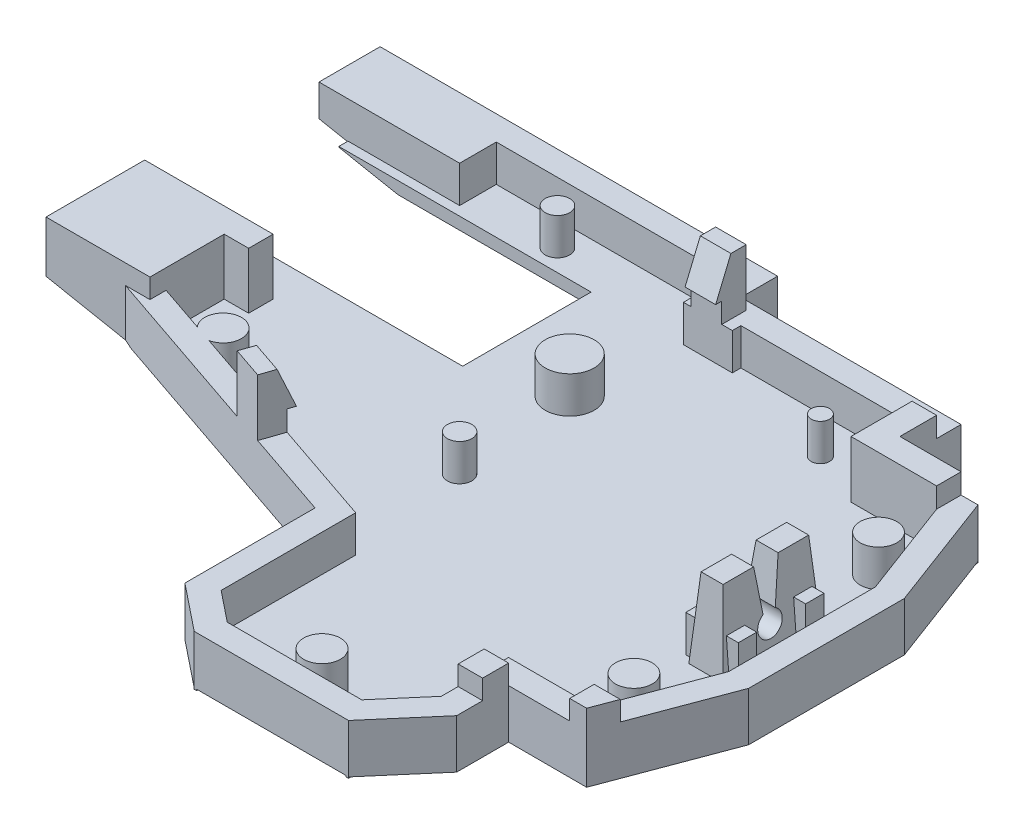
from build123d import *

# Parameters (mm, degrees)
SKETCH13_W           = 50
SKETCH13_H           = 45
BOSS_EXTRUDE4_DEPTH  = 1.6
SKETCH14_W           = 10
SKETCH14_H           = 8
CUT_EXTRUDE6_DEPTH   = 2.6
SKETCH15_W           = 18
SKETCH15_H           = 3
CUT_EXTRUDE7_DEPTH   = 2.6
SKETCH16_W           = 4
SKETCH16_H           = 0.7
CUT_EXTRUDE8_DEPTH   = 2.6
CUT_EXTRUDE9_DEPTH   = 2.6
SKETCH18_W           = 21.109590793
SKETCH18_H           = 22.840524871
CUT_EXTRUDE10_DEPTH  = 2.6
CUT_EXTRUDE11_DEPTH  = 2.6
SKETCH22_W           = 2
SKETCH22_H           = 3
CUT_EXTRUDE12_DEPTH  = 2.6
CUT_EXTRUDE13_DEPTH  = 2.6
CUT_EXTRUDE14_DEPTH  = 2.6
SKETCH25_W           = 2.8
SKETCH25_H           = 8
CUT_EXTRUDE15_DEPTH  = 2.6
BOSS_EXTRUDE6_DEPTH  = 6
SKETCH30_W           = 2.8
SKETCH30_H           = 8
BOSS_EXTRUDE7_DEPTH  = 3.5
CUT_EXTRUDE16_DEPTH  = 4.6
SKETCH32_W           = 2.8
SKETCH32_H           = 8
BOSS_EXTRUDE8_DEPTH  = 4.6
CUT_EXTRUDE18_DEPTH  = 4.6
SKETCH37_R           = 1
CUT_EXTRUDE19_DEPTH  = 4.6
CUT_EXTRUDE20_DEPTH  = 4.6
CUT_EXTRUDE21_START  = 6
CUT_EXTRUDE21_DEPTH  = 20.059798
BOSS_EXTRUDE9_DEPTH  = 4.6
SKETCH44_W           = 4.3
SKETCH44_H           = 1.5
BOSS_EXTRUDE11_DEPTH = 3
SKETCH45_R           = 1.5
SKETCH45_R_2         = 1
SKETCH45_R_3         = 1.999622229
SKETCH45_R_4         = 1.503341979
SKETCH45_R_5         = 0.75
BOSS_EXTRUDE12_DEPTH = 3
SKETCH46_W           = 2.5
SKETCH46_H           = 2
SKETCH46_W_2         = 2
BOSS_EXTRUDE13_DEPTH = 1.65
SKETCH47_W           = 3
SKETCH47_H           = 3
BOSS_EXTRUDE14_DEPTH = 3
SKETCH48_W           = 2
SKETCH48_H           = 16.336241737
CUT_EXTRUDE22_DEPTH  = 3
SKETCH49_W           = 21.336241737
SKETCH49_H           = 3
BOSS_EXTRUDE15_DEPTH = 13
SKETCH50_W           = 67
SKETCH50_H           = 49
BOSS_EXTRUDE16_DEPTH = 3
SKETCH51_W           = 5
SKETCH51_H           = 11
BOSS_EXTRUDE17_DEPTH = 15.6
CUT_EXTRUDE23_DEPTH  = 1.65
SKETCH53_W           = 2
SKETCH53_H           = 2.129349353
BOSS_EXTRUDE18_DEPTH = 1.6
SKETCH55_W           = 2.5
SKETCH55_H           = 2.5
BOSS_EXTRUDE20_DEPTH = 3
CUT_EXTRUDE24_DEPTH  = 3
SKETCH58_W           = 20
SKETCH58_H           = 10.5
SKETCH58_W_2         = 2
SKETCH58_H_2         = 2
CUT_EXTRUDE29_DEPTH  = 1
BOSS_EXTRUDE21_DEPTH = 3
BOSS_EXTRUDE22_REACH = 41.731
SKETCH61_W           = 2.5
SKETCH61_H           = 1.65
CUT_EXTRUDE30_DEPTH  = 3
CUT_EXTRUDE31_REACH  = 43.731
SKETCH64_W           = 2.551500858
SKETCH64_H           = 4.310788114
CUT_EXTRUDE32_DEPTH  = 4.65
SKETCH65_W           = 2
SKETCH65_H           = 2
BOSS_EXTRUDE23_DEPTH = 4
SKETCH66_W           = 2
SKETCH66_H           = 2
BOSS_EXTRUDE24_DEPTH = 1.6
SKETCH67_W           = 2.5
SKETCH67_H           = 2
BOSS_EXTRUDE25_DEPTH = 3
CUT_EXTRUDE33_DEPTH  = 3
BOSS_EXTRUDE26_DEPTH = 1.65
SKETCH70_W           = 5.055009343
SKETCH70_H           = 5.560438358
CUT_EXTRUDE34_DEPTH  = 3
BOSS_EXTRUDE27_DEPTH = 3
CUT_EXTRUDE35_DEPTH  = 3
BOSS_EXTRUDE28_REACH = 39.863
CUT_EXTRUDE36_DEPTH  = 3
FILLET8_R            = 1
SKETCH76_W           = 7
SKETCH76_H           = 14.5
BOSS_EXTRUDE29_DEPTH = 14.5
BOSS_EXTRUDE30_DEPTH = 2
CUT_EXTRUDE37_DEPTH  = 2
BOSS_EXTRUDE31_DEPTH = 2.684479
SKETCH85_W           = 30.566158209
SKETCH85_H           = 1.725230041
BOSS_EXTRUDE33_DEPTH = 3
BOSS_EXTRUDE34_DEPTH = 3
BOSS_EXTRUDE35_DEPTH = 3
SKETCH88_W           = 27.09375
SKETCH88_H           = 14.5
BOSS_EXTRUDE36_DEPTH = 1.6
SKETCH90_W           = 7
SKETCH90_H           = 14.5
BOSS_EXTRUDE37_DEPTH = 1.6
SKETCH93_W           = 5
SKETCH93_H           = 11
BOSS_EXTRUDE38_DEPTH = 0.5
SKETCH94_W           = 8.605758832
SKETCH94_H           = 2
BOSS_EXTRUDE39_DEPTH = 15.6
SKETCH96_W           = 8.605758832
SKETCH96_H           = 2
BOSS_EXTRUDE40_DEPTH = 0.5
SKETCH97_W           = 2
SKETCH97_H           = 49
BOSS_EXTRUDE41_DEPTH = 19.1
SKETCH98_W           = 69
SKETCH98_H           = 2
BOSS_EXTRUDE42_DEPTH = 19.1
SKETCH99_W           = 2
SKETCH99_H           = 3
BOSS_EXTRUDE43_DEPTH = 2.087376
SKETCH100_W          = 2
SKETCH100_H          = 51
BOSS_EXTRUDE45_DEPTH = 19.1
SKETCH101_W          = 71
SKETCH101_H          = 2
BOSS_EXTRUDE46_DEPTH = 19.1
BOSS_EXTRUDE47_DEPTH = 16.1
BOSS_EXTRUDE48_DEPTH = 16.1
FILLET9_R            = 2
SKETCH105_OUTSIDE_W  = 91.128
SKETCH105_OUTSIDE_H  = 73.128
CUT_EXTRUDE38_DEPTH  = 3
SKETCH106_W          = 77.0560479
SKETCH106_H          = 58.523580684
CUT_EXTRUDE39_DEPTH  = 20.1
SKETCH107_W          = 13.37564089
SKETCH107_H          = 6.179627402
CUT_EXTRUDE40_DEPTH  = 11.5
CUT_EXTRUDE41_DEPTH  = 4
SKETCH114_W          = 66.336817547
SKETCH114_H          = 51.668552302
CUT_EXTRUDE42_DEPTH  = 2
BOSS_EXTRUDE49_DEPTH = 6.5
SKETCH116_W          = 0.628599621
SKETCH116_H          = 10.5
CUT_EXTRUDE43_DEPTH  = 6.5
SKETCH117_W          = 8.5
SKETCH117_H          = 8.070282703
BOSS_EXTRUDE50_DEPTH = 1.6
SKETCH121_W          = 41.947556189
SKETCH121_H          = 104.538908281
CUT_EXTRUDE44_DEPTH  = 2.374278057
SKETCH122_W          = 0.2
SKETCH122_H          = 0.2
BOSS_EXTRUDE51_DEPTH = 0.1


with BuildPart() as part:
    # Sketch13 → Boss-Extrude4 (new body)
    with BuildSketch(Plane(origin=(0, 0, 0), x_dir=(1, 0, 0), z_dir=(0, 1, 0))):
        with Locations((25, -22.5)):
            Rectangle(SKETCH13_W, SKETCH13_H)
    extrude(amount=BOSS_EXTRUDE4_DEPTH)

    # Sketch14 → Cut-Extrude6 (cut, through all)
    with BuildSketch(Plane(origin=(0, 1.6, 0), x_dir=(1, 0, 0), z_dir=(0, 1, 0))):
        with Locations((45, -4)):
            Rectangle(SKETCH14_W, SKETCH14_H)
    extrude(amount=-CUT_EXTRUDE6_DEPTH, mode=Mode.SUBTRACT)

    # Sketch15 → Cut-Extrude7 (cut, through all)
    with BuildSketch(Plane(origin=(0, 1.6, 0), x_dir=(1, 0, 0), z_dir=(0, 1, 0))):
        with Locations((31, -1.5)):
            Rectangle(SKETCH15_W, SKETCH15_H)
    extrude(amount=-CUT_EXTRUDE7_DEPTH, mode=Mode.SUBTRACT)

    # Sketch16 → Cut-Extrude8 (cut, through all)
    with BuildSketch(Plane(origin=(0, 1.6, 0), x_dir=(1, 0, 0), z_dir=(0, 1, 0))):
        with Locations((24, -3.35)):
            Rectangle(SKETCH16_W, SKETCH16_H)
    extrude(amount=-CUT_EXTRUDE8_DEPTH, mode=Mode.SUBTRACT)

    # Sketch17 → Cut-Extrude9 (cut, through all)
    with BuildSketch(Plane(origin=(0, 1.6, 0), x_dir=(1, 0, 0), z_dir=(0, 1, 0))):
        Polygon((47, -8), (50, -16), (65.881056194, -16), (65.881056194, 17.957346821), (47, 17.957346821), align=None)
    extrude(amount=-CUT_EXTRUDE9_DEPTH, mode=Mode.SUBTRACT)

    # Sketch18 → Cut-Extrude10 (cut, through all)
    with BuildSketch(Plane(origin=(0, 1.6, 0), x_dir=(1, 0, 0), z_dir=(0, 1, 0))):
        with Locations((50.554795396, -47.420262436)):
            Rectangle(SKETCH18_W, SKETCH18_H)
    extrude(amount=-CUT_EXTRUDE10_DEPTH, mode=Mode.SUBTRACT)

    # Sketch21 → Cut-Extrude11 (cut, through all)
    with BuildSketch(Plane(origin=(0, 1.6, 0), x_dir=(1, 0, 0), z_dir=(0, 1, 0))):
        Polygon((50, -28), (47, -36), (47, -49.297594069), (75.196774358, -49.297594069), (75.196774358, -28), align=None)
    extrude(amount=-CUT_EXTRUDE11_DEPTH, mode=Mode.SUBTRACT)

    # Sketch22 → Cut-Extrude12 (cut, through all)
    with BuildSketch(Plane(origin=(0, 1.6, 0), x_dir=(1, 0, 0), z_dir=(0, 1, 0))):
        with Locations((1, -20.836241737)):
            Rectangle(SKETCH22_W, SKETCH22_H)
    extrude(amount=-CUT_EXTRUDE12_DEPTH, mode=Mode.SUBTRACT)

    # Sketch23 → Cut-Extrude13 (cut, through all)
    with BuildSketch(Plane(origin=(0, 1.6, 0), x_dir=(1, 0, 0), z_dir=(0, 1, 0))):
        Polygon((23.5, -45), (23.5, -32), (0, -26.336241737), (-30.2261683, -26.336241737), (-30.2261683, -63.188280898), (23.5, -63.188280898), align=None)
    extrude(amount=-CUT_EXTRUDE13_DEPTH, mode=Mode.SUBTRACT)

    # Sketch24 → Cut-Extrude14 (cut, through all)
    with BuildSketch(Plane(origin=(0, 1.6, 0), x_dir=(1, 0, 0), z_dir=(0, 1, 0))):
        Polygon((23.5, -43), (7.491129632, -43), (7.491129632, -69.550234766), (44.754002286, -69.550234766), (44.754002286, -41.5), (40, -41.5), (37, -45), (26, -45), align=None)
    extrude(amount=-CUT_EXTRUDE14_DEPTH, mode=Mode.SUBTRACT)

    # Sketch25 → Cut-Extrude15 (cut, through all)
    with BuildSketch(Plane(origin=(0, 1.6, 0), x_dir=(1, 0, 0), z_dir=(0, 1, 0))):
        with Locations((46.200745069, -22.059797812)):
            Rectangle(SKETCH25_W, SKETCH25_H)
    extrude(amount=-CUT_EXTRUDE15_DEPTH, mode=Mode.SUBTRACT)

    # Sketch28 → Boss-Extrude6 (add)
    with BuildSketch(Plane.XZ):
        Polygon((42, 38), (42, 42.239848152), (37.919869845, 47), (25.298437881, 47), (21.5, 43.961249695), (21.5, 33.575244456), (-2, 27.911486193), (-2, -2), (24, -2), (24, 1), (42, 1), (42, 6), (48.386000936, 6), (52, 15.637330836), (52, 28.362669164), (48.386000936, 38), align=None)
    extrude(amount=BOSS_EXTRUDE6_DEPTH)

    # Sketch30 → Boss-Extrude7 (add)
    with BuildSketch(Plane(origin=(0, 0, 0), x_dir=(1, 0, 0), z_dir=(0, 1, 0))):
        with Locations((46.200745069, -22.059797812)):
            Rectangle(SKETCH30_W, SKETCH30_H)
    extrude(amount=BOSS_EXTRUDE7_DEPTH)

    # Sketch31 → Cut-Extrude16 (cut)
    with BuildSketch(Plane(origin=(0, 1.6, 0), x_dir=(1, 0, 0), z_dir=(0, 1, 0))):
        Polygon((37, -45), (40, -41.5), (40, -36), (47, -36), (50, -28), (50, -16), (47, -8), (40, -8), (40, -3), (26, -3), (26, -3.7), (22, -3.7), (22, 0), (0, 0), (0, -19.336241737), (2, -19.336241737), (2, -22.336241737), (0, -22.336241737), (0, -26.336241737), (23.5, -32), (23.5, -43), (26, -45), align=None)
    extrude(amount=-CUT_EXTRUDE16_DEPTH, mode=Mode.SUBTRACT)

    # Sketch32 → Boss-Extrude8 (add)
    with BuildSketch(Plane.XZ.offset(-1.6)):
        with Locations((46.200745069, 22.059797812)):
            Rectangle(SKETCH32_W, SKETCH32_H)
    extrude(amount=BOSS_EXTRUDE8_DEPTH)

    # Sketch35 → Cut-Extrude18 (cut)
    with BuildSketch(Plane(origin=(47.600745069, 0, 0), x_dir=(0, 0, -1), z_dir=(1, 0, 0))):
        Polygon((-22.059797812, 0), (-21.559797812, 0), (-21.059797812, 3.5), (-21.297672794, 5.165124873), (-23.257672794, 4.885124873), (-23.059797812, 3.5), (-22.559797812, 0), align=None)
    extrude(amount=-CUT_EXTRUDE18_DEPTH, mode=Mode.SUBTRACT)

    # Sketch37 → Cut-Extrude19 (cut)
    with BuildSketch(Plane(origin=(47.600745069, 0, 0), x_dir=(0, 0, -1), z_dir=(1, 0, 0))):
        with Locations((-22.059797812, -0.866025404)):
            Circle(SKETCH37_R)
    extrude(amount=-CUT_EXTRUDE19_DEPTH, mode=Mode.SUBTRACT)

    # Sketch39 → Cut-Extrude20 (cut)
    with BuildSketch(Plane.ZY.offset(-44.800745069)):
        Polygon((25.559797812, 3.5), (26.059797812, -3), (27.906381513, -2.8579551), (27.406381513, 3.6420449), align=None)
        Polygon((18.559797812, 3.5), (18.059797812, -3), (15.957253652, -2.838265834), (16.455739093, 3.6420449), align=None)
    extrude(amount=-CUT_EXTRUDE20_DEPTH, mode=Mode.SUBTRACT)

    # Sketch41 → Cut-Extrude21 (cut)
    with BuildSketch(Plane.XY.offset(CUT_EXTRUDE21_START)):
        Polygon((45.300745069, 3.5), (44.800745069, -3), (43.414957387, -2.893400947), (43.940591177, 3.939838325), align=None)
        Polygon((47.100745069, 3.5), (47.600745069, -3), (49.658968536, -2.841675118), (49.137313656, 3.939838325), align=None)
    extrude(amount=CUT_EXTRUDE21_DEPTH, mode=Mode.SUBTRACT)

    # Sketch43 → Boss-Extrude9 (add)
    with BuildSketch(Plane(origin=(0, 0, 0), x_dir=(1, 0, 0), z_dir=(0, 1, 0))):
        Polygon((47, -8), (50, -16), (51.170411472, -13.425094762), (48.386000936, -6), (42.818763345, -6), (42.818763345, -8), align=None)
    extrude(amount=-BOSS_EXTRUDE9_DEPTH)

    # Sketch44 → Boss-Extrude11 (add)
    with BuildSketch(Plane(origin=(0, -3, 0), x_dir=(1, 0, 0), z_dir=(0, 1, 0))):
        with Locations((46.200745069, -19.309797812)):
            Rectangle(SKETCH44_W, SKETCH44_H)
        with Locations((46.200745069, -24.809797812)):
            Rectangle(SKETCH44_W, SKETCH44_H)
    extrude(amount=BOSS_EXTRUDE11_DEPTH)

    # Sketch45 → Boss-Extrude12 (add)
    with BuildSketch(Plane(origin=(0, -3, 0), x_dir=(1, 0, 0), z_dir=(0, 1, 0))):
        with Locations((46.25, -12)):
            Circle(SKETCH45_R)
        with Locations((46.25, -32)):
            Circle(SKETCH45_R)
        with Locations((22, -22)):
            Circle(SKETCH45_R_2)
        with Locations((21, -12)):
            Circle(SKETCH45_R_3)
        with Locations((31.75, -43)):
            Circle(SKETCH45_R_4)
        with Locations((35.5, -6)):
            Circle(SKETCH45_R_5)
        with Locations((10, -2)):
            Circle(SKETCH45_R_2)
        with Locations((5, -24.336241737)):
            Circle(SKETCH45_R)
    extrude(amount=BOSS_EXTRUDE12_DEPTH)

    # Sketch46 → Boss-Extrude13 (add)
    with BuildSketch(Plane(origin=(0, 0, 0), x_dir=(1, 0, 0), z_dir=(0, 1, 0))):
        Polygon((14.137316506, -29.743490383), (16.567726059, -30.329245795), (16.099121729, -32.273573438), (13.668712176, -31.687818026), align=None)
        with Locations((23.883625006, -2.7)):
            Rectangle(SKETCH46_W, SKETCH46_H)
        with Locations((1, -20.932723283)):
            Rectangle(SKETCH46_W_2, SKETCH46_H)
        Polygon((47, -36), (48.872658355, -36.702246883), (49.750466959, -34.361423939), (47.877808604, -33.659177056), align=None)
        Polygon((40, -3), (40, -8), (47, -8), (47, -6), (42, -6), (42, -3), align=None)
    extrude(amount=BOSS_EXTRUDE13_DEPTH)

    # Sketch47 → Boss-Extrude14 (add)
    with BuildSketch(Plane(origin=(0, 0, 0), x_dir=(1, 0, 0), z_dir=(0, 1, 0))):
        with Locations((1.5, -1.5)):
            Rectangle(SKETCH47_W, SKETCH47_H)
    extrude(amount=-BOSS_EXTRUDE14_DEPTH)

    # Sketch48 → Cut-Extrude22 (cut)
    with BuildSketch(Plane(origin=(0, 0, 0), x_dir=(1, 0, 0), z_dir=(0, 1, 0))):
        with Locations((-1, -11.168120869)):
            Rectangle(SKETCH48_W, SKETCH48_H)
    extrude(amount=-CUT_EXTRUDE22_DEPTH, mode=Mode.SUBTRACT)

    # Sketch49 → Boss-Extrude15 (add)
    with BuildSketch(Plane.ZY.offset(2)):
        with Locations((8.668120869, -4.5)):
            Rectangle(SKETCH49_W, SKETCH49_H)
    extrude(amount=BOSS_EXTRUDE15_DEPTH)

    # Sketch50 → Boss-Extrude16 (add)
    with BuildSketch(Plane.XZ.offset(6)):
        with Locations((18.5, 22.5)):
            Rectangle(SKETCH50_W, SKETCH50_H)
    extrude(amount=-BOSS_EXTRUDE16_DEPTH)

    # Sketch51 → Boss-Extrude17 (add)
    with BuildSketch(Plane(origin=(0, -3, 0), x_dir=(1, 0, 0), z_dir=(0, 1, 0))):
        with Locations((49.5, -41.5)):
            Rectangle(SKETCH51_W, SKETCH51_H)
    extrude(amount=BOSS_EXTRUDE17_DEPTH)

    # Sketch52 → Cut-Extrude23 (cut)
    with BuildSketch(Plane(origin=(0, 1.65, 0), x_dir=(1, 0, 0), z_dir=(0, 1, 0))):
        Polygon((47.877808604, -33.659177056), (47, -36), (49.136000936, -36), (49.750466959, -34.361423939), align=None)
    extrude(amount=-CUT_EXTRUDE23_DEPTH, mode=Mode.SUBTRACT)

    # Sketch53 → Boss-Extrude18 (add)
    with BuildSketch(Plane(origin=(0, 0, 0), x_dir=(1, 0, 0), z_dir=(0, 1, 0))):
        with Locations((41, -39.055249399)):
            Rectangle(SKETCH53_W, SKETCH53_H)
    extrude(amount=BOSS_EXTRUDE18_DEPTH)

    # Sketch55 → Boss-Extrude20 (add)
    with BuildSketch(Plane(origin=(0, 1.65, 0), x_dir=(1, 0, 0), z_dir=(0, 1, 0))):
        with Locations((23.883625006, -2.95)):
            Rectangle(SKETCH55_W, SKETCH55_H)
    extrude(amount=BOSS_EXTRUDE20_DEPTH)

    # Sketch56 → Cut-Extrude24 (cut)
    with BuildSketch(Plane(origin=(25.133625006, 0, 0), x_dir=(0, 0, -1), z_dir=(1, 0, 0))):
        Polygon((-4.2, 1.65), (-2.95, 4.65), (-2.95, 7.68728323), (-6.59715338, 7.68728323), (-6.59715338, 1.641289328), align=None)
    extrude(amount=-CUT_EXTRUDE24_DEPTH, mode=Mode.SUBTRACT)

    # Sketch58 → Cut-Extrude29 (cut)
    with BuildSketch(Plane(origin=(0, -3, 0), x_dir=(1, 0, 0), z_dir=(0, 1, 0))):
        with Locations((4.5, -9)):
            Rectangle(SKETCH58_W, SKETCH58_H)
        with Locations((1, -18.248866233)):
            Rectangle(SKETCH58_W_2, SKETCH58_H_2)
    extrude(amount=-CUT_EXTRUDE29_DEPTH, mode=Mode.SUBTRACT)

    # Sketch60 → Boss-Extrude21 (add)
    with BuildSketch(Plane(origin=(0, -3, 0), x_dir=(1, 0, 0), z_dir=(0, 1, 0))):
        Polygon((0, -24), (23.5, -32), (0, -26.336241737), align=None)
    extrude(amount=BOSS_EXTRUDE21_DEPTH)

    # Boss-Extrude22: up to this face of the body (flat: up to its plane)
    boss_extrude22_end = Plane(part.part.faces().sort_by_distance((14.401539714, -1.5, 28.902651818))[0])
    # Sketch61 → Boss-Extrude22 (add, up to the picked face)
    with BuildSketch(Plane(origin=(-5.998871461, 0, 24.890447788), x_dir=(-0.972163821, 0, -0.234302165), z_dir=(0.234302165, 0, -0.972163821)), mode=Mode.PRIVATE) as boss_extrude22_sk1:
        with Locations((-21.962751827, 0.825)):
            Rectangle(SKETCH61_W, SKETCH61_H)
    boss_extrude22_tool1 = split(extrude(boss_extrude22_sk1.sketch, amount=BOSS_EXTRUDE22_REACH, mode=Mode.PRIVATE), bisect_by=boss_extrude22_end, keep=Keep.BOTH, mode=Mode.PRIVATE)
    add(boss_extrude22_tool1.solids().sort_by_distance((15.352521, 0.825, 30.036368))[0])

    # Sketch62 → Cut-Extrude30 (cut)
    with BuildSketch(Plane(origin=(0, 0, 0), x_dir=(1, 0, 0), z_dir=(0, 1, 0))):
        Polygon((0, -26), (-0.545193502, -28.262110548), (-9.931116312, -26), (-9.25988925, -22.847697277), align=None)
    extrude(amount=-CUT_EXTRUDE30_DEPTH, mode=Mode.SUBTRACT)

    # Cut-Extrude31: up to this face of the body (flat: up to its plane)
    cut_extrude31_end = Plane(part.part.faces().sort_by_distance((-1, -1.5, 25.659574468))[0])
    # Sketch63 → Cut-Extrude31 (cut, up to the picked face)
    with BuildSketch(Plane(origin=(-6.46747579, 0, 26.834775431), x_dir=(0.972163821, 0, 0.234302165), z_dir=(-0.234302165, 0, 0.972163821)), mode=Mode.PRIVATE) as cut_extrude31_sk1:
        Polygon((20.712751827, 0), (6.091856288, 0), (6.091856288, -3), (28.768274623, -3), (28.768274623, 0), (23.212751827, 0), (23.212751827, 1.65), (20.712751827, 1.65), align=None)
    cut_extrude31_tool1 = split(extrude(cut_extrude31_sk1.sketch, amount=-CUT_EXTRUDE31_REACH, mode=Mode.PRIVATE), bisect_by=cut_extrude31_end, keep=Keep.BOTH, mode=Mode.PRIVATE)
    add(cut_extrude31_tool1.solids().sort_by_distance((10.72932, -1.367082, 30.979392))[0], mode=Mode.SUBTRACT)

    # Sketch64 → Cut-Extrude32 (cut)
    with BuildSketch(Plane(origin=(0, 1.65, 0), x_dir=(1, 0, 0), z_dir=(0, 1, 0))):
        with Locations((1.275750429, -20.806985271)):
            Rectangle(SKETCH64_W, SKETCH64_H)
    extrude(amount=-CUT_EXTRUDE32_DEPTH, mode=Mode.SUBTRACT)

    # Sketch65 → Boss-Extrude23 (add)
    with BuildSketch(Plane(origin=(0, -4, 0), x_dir=(1, 0, 0), z_dir=(0, 1, 0))):
        with Locations((1, -18.248866233)):
            Rectangle(SKETCH65_W, SKETCH65_H)
    extrude(amount=BOSS_EXTRUDE23_DEPTH)

    # Sketch66 → Boss-Extrude24 (add)
    with BuildSketch(Plane(origin=(0, 0, 0), x_dir=(1, 0, 0), z_dir=(0, 1, 0))):
        with Locations((1, -18.248866233)):
            Rectangle(SKETCH66_W, SKETCH66_H)
    extrude(amount=BOSS_EXTRUDE24_DEPTH)

    # Sketch67 → Boss-Extrude25 (add)
    with BuildSketch(Plane(origin=(0, 1.6, 0), x_dir=(1, 0, 0), z_dir=(0, 1, 0))):
        with Locations((1.25, -18.248866233)):
            Rectangle(SKETCH67_W, SKETCH67_H)
    extrude(amount=BOSS_EXTRUDE25_DEPTH)

    # Sketch68 → Cut-Extrude33 (cut)
    with BuildSketch(Plane(origin=(0, 0, 17.248866233), x_dir=(-1, 0, 0), z_dir=(0, 0, -1))):
        Polygon((-2.5, 1.6), (-1.25, 4.6), (-1.25, 6.77486743), (-4.497451498, 6.77486743), (-4.497451498, 1.567063174), align=None)
    extrude(amount=-CUT_EXTRUDE33_DEPTH, mode=Mode.SUBTRACT)

    # Sketch69 → Boss-Extrude26 (add)
    with BuildSketch(Plane(origin=(0, 1.65, 0), x_dir=(1, 0, 0), z_dir=(0, 1, 0))):
        Polygon((14.344636536, -28.883280523), (16.885898362, -29.748390932), (16.275756374, -31.540683021), (13.734494548, -30.675572612), align=None)
    extrude(amount=-BOSS_EXTRUDE26_DEPTH)

    # Sketch70 → Cut-Extrude34 (cut)
    with BuildSketch(Plane.XY.offset(19.248866233)):
        with Locations((-0.027504672, 4.380219179)):
            Rectangle(SKETCH70_W, SKETCH70_H)
    extrude(amount=-CUT_EXTRUDE34_DEPTH, mode=Mode.SUBTRACT)

    # Sketch71 → Boss-Extrude27 (add)
    with BuildSketch(Plane(origin=(0, 1.65, 0), x_dir=(1, 0, 0), z_dir=(0, 1, 0))):
        Polygon((16.275756374, -31.540683021), (17.081415869, -29.174058256), (14.559846057, -28.298525857), (13.734494548, -30.675572612), align=None)
    extrude(amount=BOSS_EXTRUDE27_DEPTH)

    # Sketch72 → Cut-Extrude35 (cut)
    with BuildSketch(Plane(origin=(24.207602216, 0, 8.240885861), x_dir=(0.322263798, 0, -0.946649906), z_dir=(0.946649906, 0, 0.322263798))):
        Polygon((-22.112897557, 1.65), (-23.362897557, 4.65), (-23.362897557, 7.694800469), (-20.734818485, 7.694800469), (-20.734818485, 1.65), align=None)
    extrude(amount=-CUT_EXTRUDE35_DEPTH, mode=Mode.SUBTRACT)

    # Boss-Extrude28: up to this face of the body (flat: up to its plane)
    boss_extrude28_end = Plane(part.part.faces().sort_by_distance((14.039565542, 0.825, 29.779426567))[0])
    # Sketch73 → Boss-Extrude28 (add, up to the picked face)
    with BuildSketch(Plane(origin=(21.761963317, 0, 7.556127878), x_dir=(-0.328007452, 0, 0.944675136), z_dir=(-0.944675136, 0, -0.328007452)), mode=Mode.PRIVATE) as boss_extrude28_sk1:
        Polygon((24.473434161, 4.65), (23.223411105, 4.65), (21.973388049, 1.65), (22.580099427, 1.65), (24.473434161, 1.65), align=None)
    boss_extrude28_tool1 = split(extrude(boss_extrude28_sk1.sketch, amount=BOSS_EXTRUDE28_REACH, mode=Mode.PRIVATE), bisect_by=boss_extrude28_end, keep=Keep.BOTH, mode=Mode.PRIVATE)
    add(boss_extrude28_tool1.solids().sort_by_distance((14.053397, 2.983333, 29.757122))[0])

    # Sketch74 → Cut-Extrude36 (cut)
    with BuildSketch(Plane(origin=(0, -4, 0), x_dir=(1, 0, 0), z_dir=(0, 1, 0))):
        with BuildLine():
            Line((6.419171569, -6.169171569), (2.580828431, -6.169171569))
            ThreePointArc((2.580828431, -6.169171569), (-0.25, -9), (2.580828431, -11.830828431))
            Line((2.580828431, -11.830828431), (6.419171569, -11.830828431))
            ThreePointArc((6.419171569, -11.830828431), (9.25, -9), (6.419171569, -6.169171569))
        make_face()
    extrude(amount=-CUT_EXTRUDE36_DEPTH, mode=Mode.SUBTRACT)

    # Fillet8
    fillet8_edges = [part.edges().sort_by_distance(p)[0] for p in [
        (-0.25, -6, 9),
        (4.5, -6, 6.169171569),
        (9.25, -6, 9),
        (4.5, -6, 11.830828431),
    ]]
    fillet(fillet8_edges, radius=FILLET8_R)

    # Sketch76 → Boss-Extrude29 (add)
    with BuildSketch(Plane(origin=(0, -3, 0), x_dir=(1, 0, 0), z_dir=(0, 1, 0))):
        with Locations((-11.5, -39.75)):
            Rectangle(SKETCH76_W, SKETCH76_H)
    extrude(amount=BOSS_EXTRUDE29_DEPTH)

    # Sketch79 → Boss-Extrude30 (add)
    with BuildSketch(Plane(origin=(21.66634039, 0, 7.375775452), x_dir=(-0.322263798, 0, 0.946649906), z_dir=(-0.946649906, 0, -0.322263798))):
        Polygon((22.719597745, 0), (24.612897557, 0), (24.612897557, 4.65), (23.362851444, 4.65), (22.112805332, 1.65), (22.719597745, 1.65), align=None)
    extrude(amount=BOSS_EXTRUDE30_DEPTH)

    # Sketch80 → Cut-Extrude37 (cut)
    with BuildSketch(Plane(origin=(24.207602216, 0, 8.240885861), x_dir=(0.322263798, 0, -0.946649906), z_dir=(0.946649906, 0, 0.322263798))):
        Polygon((-22.112897557, 1.65), (-23.362897557, 4.65), (-24.612897557, 4.65), (-24.612897557, 0), (-22.719597745, 0), (-22.719597745, 1.65), align=None)
    extrude(amount=-CUT_EXTRUDE37_DEPTH, mode=Mode.SUBTRACT)

    # Sketch83 → Boss-Extrude31 (add)
    with BuildSketch(Plane(origin=(19.773040578, 0, 6.731247856), x_dir=(-0.322263798, 0, 0.946649906), z_dir=(-0.946649906, 0, -0.322263798))):
        Polygon((22.719597745, 1.65), (22.719597745, 0), (24.612897557, 0), (24.612897557, 4.65), (23.362851444, 4.65), (22.112805332, 1.65), align=None)
    extrude(amount=-BOSS_EXTRUDE31_DEPTH)

    # Sketch85 → Boss-Extrude33 (add)
    with BuildSketch(Plane(origin=(0, -3, 0), x_dir=(1, 0, 0), z_dir=(0, 1, 0))):
        with Locations((7.283079105, -33.362615021)):
            Rectangle(SKETCH85_W, SKETCH85_H)
    extrude(amount=BOSS_EXTRUDE33_DEPTH)

    # Sketch86 → Boss-Extrude34 (add)
    with BuildSketch(Plane(origin=(0, -3, 0), x_dir=(1, 0, 0), z_dir=(0, 1, 0))):
        Polygon((21.5, -43.961249695), (21.5, -34.225230041), (-8, -34.225230041), (-8, -47), (25.298437881, -47), align=None)
    extrude(amount=BOSS_EXTRUDE34_DEPTH)

    # Sketch87 → Boss-Extrude35 (add)
    with BuildSketch(Plane(origin=(0, -3, 0), x_dir=(1, 0, 0), z_dir=(0, 1, 0))):
        Polygon((37.919869845, -47), (47, -47), (47, -38), (42, -38), (42, -42.239848152), align=None)
    extrude(amount=BOSS_EXTRUDE35_DEPTH)

    # Sketch88 → Boss-Extrude36 (add)
    with BuildSketch(Plane(origin=(0, 0, 0), x_dir=(1, 0, 0), z_dir=(0, 1, 0))):
        with Locations((5.546875, -39.75)):
            Rectangle(SKETCH88_W, SKETCH88_H)
    extrude(amount=BOSS_EXTRUDE36_DEPTH)

    # Sketch90 → Boss-Extrude37 (add)
    with BuildSketch(Plane(origin=(0, 11.5, 0), x_dir=(1, 0, 0), z_dir=(0, 1, 0))):
        with Locations((-11.5, -39.75)):
            Rectangle(SKETCH90_W, SKETCH90_H)
    extrude(amount=BOSS_EXTRUDE37_DEPTH)

    # Sketch93 → Boss-Extrude38 (add)
    with BuildSketch(Plane(origin=(0, 12.6, 0), x_dir=(1, 0, 0), z_dir=(0, 1, 0))):
        with Locations((49.5, -41.5)):
            Rectangle(SKETCH93_W, SKETCH93_H)
    extrude(amount=BOSS_EXTRUDE38_DEPTH)

    # Sketch94 → Boss-Extrude39 (add)
    with BuildSketch(Plane(origin=(0, -3, 0), x_dir=(1, 0, 0), z_dir=(0, 1, 0))):
        with Locations((5.421445221, -31.5)):
            Rectangle(SKETCH94_W, SKETCH94_H)
    extrude(amount=BOSS_EXTRUDE39_DEPTH)

    # Sketch96 → Boss-Extrude40 (add)
    with BuildSketch(Plane(origin=(0, 12.6, 0), x_dir=(1, 0, 0), z_dir=(0, 1, 0))):
        with Locations((5.421445221, -31.5)):
            Rectangle(SKETCH96_W, SKETCH96_H)
    extrude(amount=BOSS_EXTRUDE40_DEPTH)

    # Sketch97 → Boss-Extrude41 (add)
    with BuildSketch(Plane.XZ.offset(6)):
        with Locations((-16, 22.5)):
            Rectangle(SKETCH97_W, SKETCH97_H)
    extrude(amount=-BOSS_EXTRUDE41_DEPTH)

    # Sketch98 → Boss-Extrude42 (add)
    with BuildSketch(Plane.XZ.offset(6)):
        with Locations((17.5, 48)):
            Rectangle(SKETCH98_W, SKETCH98_H)
    extrude(amount=-BOSS_EXTRUDE42_DEPTH)

    # Sketch99 → Boss-Extrude43 (add)
    with BuildSketch(Plane(origin=(0, 0, 19.336241737), x_dir=(-1, 0, 0), z_dir=(0, 0, -1))):
        with Locations((1, -1.5)):
            Rectangle(SKETCH99_W, SKETCH99_H)
    extrude(amount=BOSS_EXTRUDE43_DEPTH)

    # Sketch100 → Boss-Extrude45 (add)
    with BuildSketch(Plane.XZ.offset(6)):
        with Locations((53, 23.5)):
            Rectangle(SKETCH100_W, SKETCH100_H)
    extrude(amount=-BOSS_EXTRUDE45_DEPTH)

    # Sketch101 → Boss-Extrude46 (add)
    with BuildSketch(Plane.XZ.offset(6)):
        with Locations((18.5, -3)):
            Rectangle(SKETCH101_W, SKETCH101_H)
    extrude(amount=-BOSS_EXTRUDE46_DEPTH)

    # Sketch102 → Boss-Extrude47 (add)
    with BuildSketch(Plane(origin=(0, -3, 0), x_dir=(1, 0, 0), z_dir=(0, 1, 0))):
        with BuildLine():
            Line((50, 2), (50, 2.836676417))
            Line((50, 2.836676417), (52.928518438, 2.836676417))
            Line((52.928518438, 2.836676417), (52.928518438, 0))
            Line((52.928518438, 0), (52, 0))
            ThreePointArc((52, 0), (51.414213562, 1.414213562), (50, 2))
        make_face()
    extrude(amount=BOSS_EXTRUDE47_DEPTH)

    # Sketch103 → Boss-Extrude48 (add)
    with BuildSketch(Plane(origin=(0, -3, 0), x_dir=(1, 0, 0), z_dir=(0, 1, 0))):
        with BuildLine():
            Line((-13, 2), (-13, 3.319267165))
            Line((-13, 3.319267165), (-16.315139414, 3.319267165))
            Line((-16.315139414, 3.319267165), (-16.315139414, 0))
            Line((-16.315139414, 0), (-15, 0))
            ThreePointArc((-15, 0), (-14.414213562, 1.414213562), (-13, 2))
        make_face()
    extrude(amount=BOSS_EXTRUDE48_DEPTH)

    # Fillet9
    fillet9_edges = [part.edges().sort_by_distance(p)[0] for p in [
        (-17, -6, 22.5),
        (18.5, -6, 49),
        (-17, 3.55, 49),
        (54, -6, 22.5),
        (54, 3.55, 49),
        (18.5, -6, -4),
        (-17, 3.55, -4),
        (54, 3.55, -4),
    ]]
    fillet(fillet9_edges, radius=FILLET9_R)

    # Sketch105 outside → Cut-Extrude38 (cut)
    with BuildSketch(Plane(origin=(0, 13.1, 0), x_dir=(1, 0, 0), z_dir=(0, 1, 0))):
        with Locations((18.5, -22.5)):
            Rectangle(SKETCH105_OUTSIDE_W, SKETCH105_OUTSIDE_H)
        with BuildLine():
            Line((-16, 2), (-16, -47))
            ThreePointArc((-16, -47), (-15.707106781, -47.707106781), (-15, -48))
            Line((-15, -48), (52, -48))
            ThreePointArc((52, -48), (52.707106781, -47.707106781), (53, -47))
            Line((53, -47), (53, 2))
            ThreePointArc((53, 2), (52.707106781, 2.707106781), (52, 3))
            Line((52, 3), (-15, 3))
            ThreePointArc((-15, 3), (-15.707106781, 2.707106781), (-16, 2))
        make_face(mode=Mode.SUBTRACT)
    extrude(amount=-CUT_EXTRUDE38_DEPTH, mode=Mode.SUBTRACT)

    # Sketch106 → Cut-Extrude39 (cut, through all)
    with BuildSketch(Plane.XZ.offset(6)):
        with Locations((17.692589571, 21.631481201)):
            Rectangle(SKETCH106_W, SKETCH106_H)
        Polygon((-2, -2), (24, -2), (24, 1), (42, 1), (42, 6), (48.386000936, 6), (52, 15.637330836), (52, 28.362669164), (49.136000936, 36), (48.386000936, 38), (42, 37.990574723), (42, 42.239848152), (37.919869845, 47), (25.298437881, 47), (21.5, 43.961249695), (21.5, 33.319148936), (-2, 25.319148936), (-2, 17.248866233), (-8.372079234, 17.248866233), (-8.372079234, 3), (-2, 3), align=None, mode=Mode.SUBTRACT)
    extrude(amount=-CUT_EXTRUDE39_DEPTH, mode=Mode.SUBTRACT)

    # Sketch107 → Cut-Extrude40 (cut)
    with BuildSketch(Plane(origin=(0, 13.1, 0), x_dir=(1, 0, 0), z_dir=(0, 1, 0))):
        with Locations((44.784273424, -38.274312053)):
            Rectangle(SKETCH107_W, SKETCH107_H)
    extrude(amount=-CUT_EXTRUDE40_DEPTH, mode=Mode.SUBTRACT)

    # Sketch113 → Cut-Extrude41 (cut, through all)
    with BuildSketch(Plane(origin=(0, -3, 0), x_dir=(1, 0, 0), z_dir=(0, 1, 0))):
        Polygon((-6.128599621, -3), (-6.128599621, -14.861393841), (-2, -14.861393841), (-2, -17.248866233), (-9.246534053, -26.452427809), (-13.814435406, -0.657200841), (-2.974123127, 6.68981616), (-3.537653946, 5.974095989), align=None)
    extrude(amount=-CUT_EXTRUDE41_DEPTH, mode=Mode.SUBTRACT)

    # Sketch114 → Cut-Extrude42 (cut)
    with BuildSketch(Plane.XZ.offset(6)):
        with Locations((24.645555619, 22.809022442)):
            Rectangle(SKETCH114_W, SKETCH114_H)
    extrude(amount=-CUT_EXTRUDE42_DEPTH, mode=Mode.SUBTRACT)

    # Sketch115 → Boss-Extrude49 (add)
    with BuildSketch(Plane.ZY.offset(2)):
        Polygon((14.861393841, -3), (14.861393841, -4), (25.319148936, -4), (25.319148936, 0), (17.248866233, 0), (17.248866233, -3), align=None)
        Polygon((-2, 0), (-2, -4), (3, -4), (3, -3), (3, 0), align=None)
    extrude(amount=BOSS_EXTRUDE49_DEPTH)

    # Sketch116 → Cut-Extrude43 (cut)
    with BuildSketch(Plane(origin=(0, -3, 0), x_dir=(1, 0, 0), z_dir=(0, 1, 0))):
        with Locations((-5.81429981, -9)):
            Rectangle(SKETCH116_W, SKETCH116_H)
    extrude(amount=-CUT_EXTRUDE43_DEPTH, mode=Mode.SUBTRACT)

    # Sketch117 → Boss-Extrude50 (add)
    with BuildSketch(Plane(origin=(0, 0, 0), x_dir=(1, 0, 0), z_dir=(0, 1, 0))):
        with Locations((-4.25, -21.284007585)):
            Rectangle(SKETCH117_W, SKETCH117_H)
    extrude(amount=BOSS_EXTRUDE50_DEPTH)

    # Sketch121 → Cut-Extrude44 (cut, through all)
    with BuildSketch(Plane(origin=(-0.79645719, -4.097417033, 0), x_dir=(0.981627183, -0.190808995, 0), z_dir=(0.190808995, 0.981627183, 0))):
        with Locations((-1.037587354, -26.258689617)):
            Rectangle(SKETCH121_W, SKETCH121_H)
    extrude(amount=-CUT_EXTRUDE44_DEPTH, mode=Mode.SUBTRACT)

    # Sketch122 → Boss-Extrude51 (add)
    with BuildSketch(Plane.XZ.offset(4)):
        with Locations((41.9, 1.1)):
            Rectangle(SKETCH122_W, SKETCH122_H)
        with Locations((48.286000936, 6.1)):
            Rectangle(SKETCH122_W, SKETCH122_H)
        with Locations((25.398437881, 46.9)):
            Rectangle(SKETCH122_W, SKETCH122_H)
        with Locations((37.819869845, 46.9)):
            Rectangle(SKETCH122_W, SKETCH122_H)
    extrude(amount=BOSS_EXTRUDE51_DEPTH)


solid = part.part
